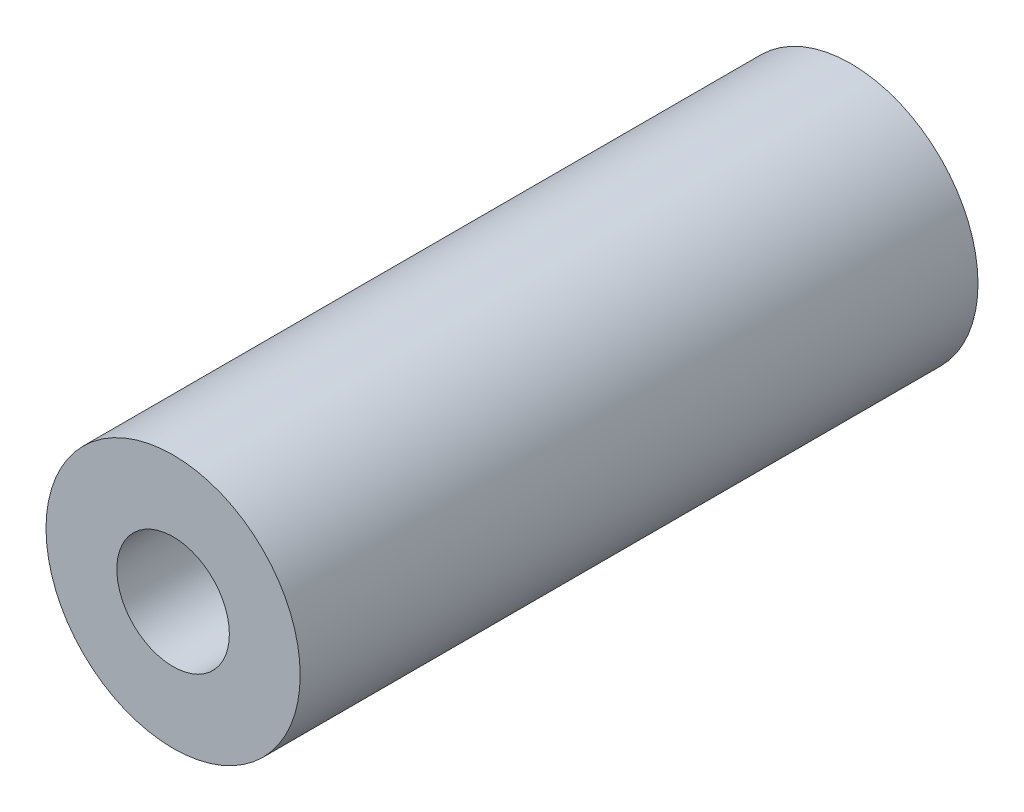
from build123d import *

# Parameters (mm, degrees)
SKETCH1_R           = 4.7625
SKETCH1_R_2         = 2.1082
EXTRUDE1_DEPTH      = 12.7
EXTRUDE1_DEPTH_BACK = 12.7


with BuildPart() as part:
    # Sketch1 → Extrude1 (new body, two sides)
    with BuildSketch(Plane.XY) as extrude1_sk:
        Circle(SKETCH1_R)
        Circle(SKETCH1_R_2, mode=Mode.SUBTRACT)
    extrude(amount=EXTRUDE1_DEPTH)
    extrude(extrude1_sk.sketch, amount=-EXTRUDE1_DEPTH_BACK)


solid = part.part
